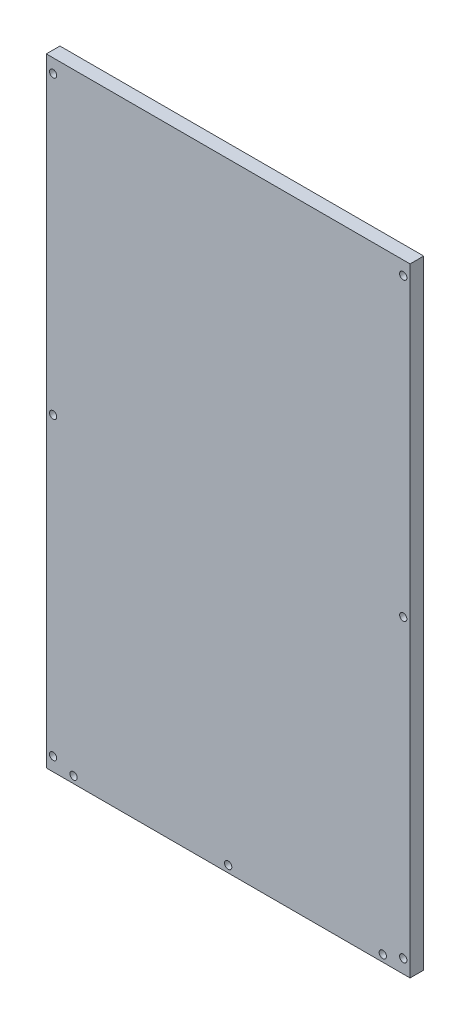
from build123d import *

# Parameters (mm, degrees)
SKETCH1_W               = 400
SKETCH1_H               = 680
BOSS_EXTRUDE1_DEPTH     = 15
SKETCH2_R               = 4
CUT_EXTRUDE1_DEPTH      = 10
LPATTERN1_COUNT         = 3
LPATTERN1_PITCH         = 325
MIRROR1_COPY_1_SKETCH_R = 4
MIRROR1_COPY_1_DEPTH    = 10
MIRROR1_COPY_2_SKETCH_R = 4
MIRROR1_COPY_2_DEPTH    = 10
SKETCH2_3_R             = 4
CUT_EXTRUDE2_DEPTH      = 10
LPATTERN2_COUNT         = 3
LPATTERN2_PITCH         = 170


with BuildPart() as part:
    # Sketch1 → Boss-Extrude1 (new body)
    with BuildSketch(Plane.XY):
        Rectangle(SKETCH1_W, SKETCH1_H)
    extrude(amount=BOSS_EXTRUDE1_DEPTH)

    # Sketch2 → Cut-Extrude1 (cut)
    with BuildSketch(Plane.XY.offset(15)):
        with Locations((192.5, 325)):
            Circle(SKETCH2_R)
    cut_extrude1 = extrude(amount=-CUT_EXTRUDE1_DEPTH, mode=Mode.SUBTRACT)

    # LPattern1: Cut-Extrude1 ×3
    with Locations(*[(0, -i * LPATTERN1_PITCH, 0) for i in range(1, LPATTERN1_COUNT)]):
        add(cut_extrude1, mode=Mode.SUBTRACT)

    # Mirror1: Cut-Extrude1 across plane
    add(cut_extrude1.mirror(Plane(origin=(0, 0, 0), x_dir=(0, 0, 1), z_dir=(1, 0, 0))), mode=Mode.SUBTRACT)

    # Mirror1 copy 1 sketch → Mirror1 copy 1 (cut)
    with BuildSketch(Plane(origin=(0, -325, 15), x_dir=(-1, 0, 0), z_dir=(0, 0, 1))):
        with Locations((192.5, -325)):
            Circle(MIRROR1_COPY_1_SKETCH_R)
    extrude(amount=-MIRROR1_COPY_1_DEPTH, mode=Mode.SUBTRACT)

    # Mirror1 copy 2 sketch → Mirror1 copy 2 (cut)
    with BuildSketch(Plane(origin=(0, -650, 15), x_dir=(-1, 0, 0), z_dir=(0, 0, 1))):
        with Locations((192.5, -325)):
            Circle(MIRROR1_COPY_2_SKETCH_R)
    extrude(amount=-MIRROR1_COPY_2_DEPTH, mode=Mode.SUBTRACT)

    # Sketch2_3 → Cut-Extrude2 (cut)
    with BuildSketch(Plane.XY.offset(15)):
        with Locations((170, -332.5)):
            Circle(SKETCH2_3_R)
    cut_extrude2 = extrude(amount=-CUT_EXTRUDE2_DEPTH, mode=Mode.SUBTRACT)

    # LPattern2: Cut-Extrude2 ×3
    with Locations(*[(-i * LPATTERN2_PITCH, 0, 0) for i in range(1, LPATTERN2_COUNT)]):
        add(cut_extrude2, mode=Mode.SUBTRACT)


solid = part.part
